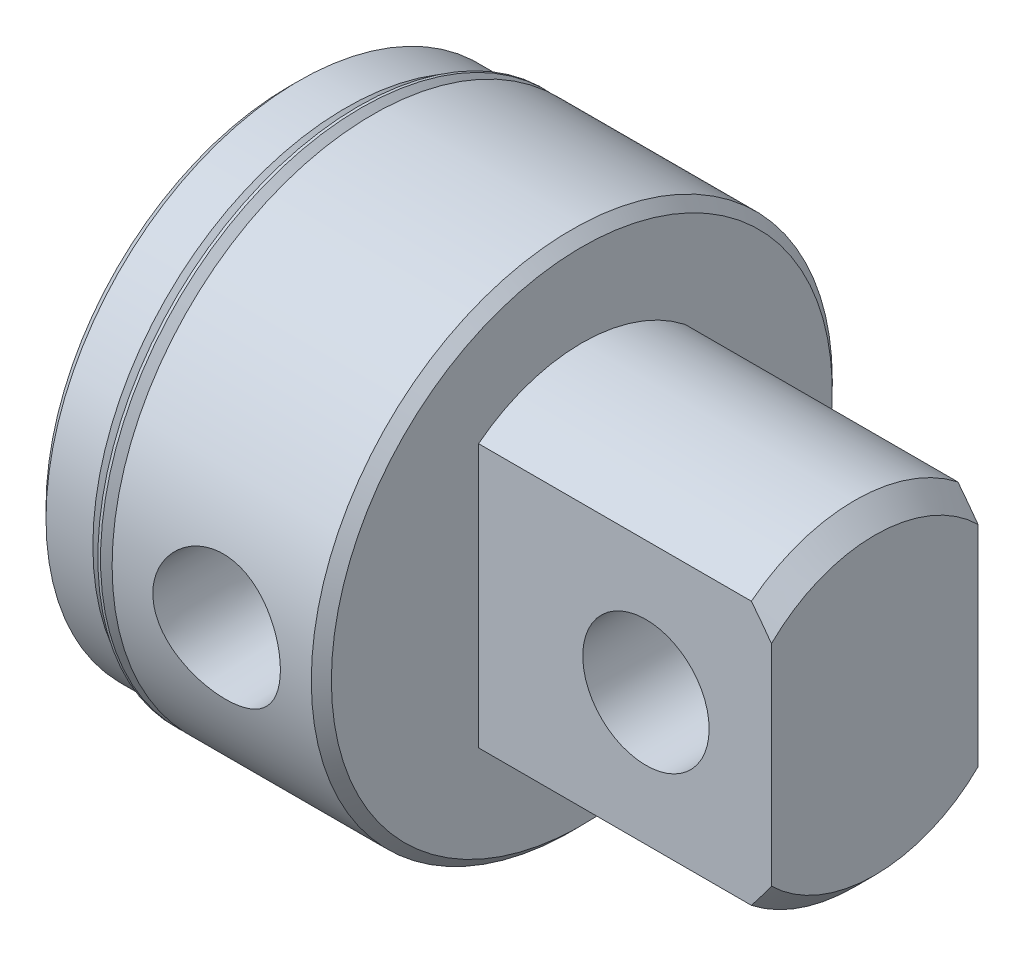
from build123d import *

# Parameters (mm, degrees)
SKETCH3_W               = 79.0702
SKETCH3_H               = 158.1404
SKETCH3_W_2             = 15.6718
SKETCH3_H_2             = 79.0702
CUT_EXTRUDE1_DEPTH      = 22.225
HOLE1_D                 = 13.5128
HOLE1_DEPTH             = 20.45208
HOLE1_TIP               = 3.900809359
SKETCH7_W               = 6.35
SKETCH7_H               = 12.3063
SKETCH9_R               = 4.79425
CUT_EXTRUDE2_DEPTH      = 11.75385
CUT_EXTRUDE2_DEPTH_BACK = 11.75385


with BuildPart() as part:
    # Sketch1 → Revolve1 (revolve)
    with BuildSketch(Plane.XY):
        Polygon((0, 0), (0, 18.43405), (0.762, 19.19605), (4.318, 19.19605), (5.334, 18.18005), (6.35, 18.18005), (6.35, 19.76755), (21.463, 19.76755), (22.225, 19.00555), (22.225, 0), align=None)
    revolve(axis=Axis((22.225, 0, 0), (-1, 0, 0)))

    # Sketch2 → Revolve2 (revolve)
    with BuildSketch(Plane.XY):
        Polygon((22.225, 0), (22.225, 12.7), (42.926, 12.7), (44.45, 11.176), (44.45, 0), align=None)
    revolve(axis=Axis((44.45, 0, 0), (-1, 0, 0)))

    # Sketch3 → Cut-Extrude1 (cut)
    with BuildSketch(Plane(origin=(44.45, 0, 0), x_dir=(0, 0, -1), z_dir=(1, 0, 0))):
        Rectangle(SKETCH3_W, SKETCH3_H)
        Rectangle(SKETCH3_W_2, SKETCH3_H_2, mode=Mode.SUBTRACT)
    extrude(amount=-CUT_EXTRUDE1_DEPTH, mode=Mode.SUBTRACT)

    # Hole1
    with Locations(Plane.ZY):
        with Locations((0, 0)):
            Hole(HOLE1_D / 2, depth=HOLE1_DEPTH)
            with Locations((0, 0, -(HOLE1_DEPTH + HOLE1_TIP / 2))):  # 120° drill point
                Cone(0, HOLE1_D / 2, HOLE1_TIP, mode=Mode.SUBTRACT)

    # Sketch6 → Cut-Revolve1 (revolve, cut)
    with BuildSketch(Plane(origin=(0, 0, 0), x_dir=(-1, 0, 0), z_dir=(0, 0.999847695, 0.017452406))):
        Polygon((-14.2748, 0), (-18.897793378, 0), (-18.897793378, 12.83335), (-19.114275925, 19.76755), (-14.2748, 19.76755), align=None)
    revolve(axis=Axis((14.2748, -0.344991317, 19.764539306), (0, 0.017452406, -0.999847695)), mode=Mode.SUBTRACT)

    # Sketch7 → Cut-Revolve2 (revolve, cut)
    with BuildSketch(Plane.XY):
        with Locations((3.175, 6.15315)):
            Rectangle(SKETCH7_W, SKETCH7_H)
    revolve(axis=Axis((6.35, 0, 0), (-1, 0, 0)), mode=Mode.SUBTRACT)

    # Sketch8 → Revolve3 (revolve)
    with BuildSketch(Plane.XY):
        with BuildLine():
            Line((5.267509175, 19.683381804), (6.216617928, 18.734273051))
            ThreePointArc((6.216617928, 18.734273051), (6.253815367, 18.64447049), (6.216617928, 18.554667928))
            Line((6.216617928, 18.554667928), (5.842, 18.18005))
            Line((5.842, 18.18005), (5.334, 18.18005))
            Line((5.334, 18.18005), (5.334, 17.92605))
            Line((5.334, 17.92605), (6.35, 17.92605))
            Line((6.35, 17.92605), (6.35, 18.888259175))
            Line((6.35, 18.888259175), (5.470709175, 19.76755))
            Line((5.470709175, 19.76755), (5.267509175, 19.76755))
            Line((5.267509175, 19.76755), (5.267509175, 19.683381804))
        make_face()
    revolve(axis=Axis((6.35, 0, 0), (-1, 0, 0)))

    # Sketch9 → Cut-Extrude2 (cut, two sides)
    with BuildSketch(Plane.XY) as cut_extrude2_sk:
        with Locations((34.925, 0)):
            Circle(SKETCH9_R)
    extrude(amount=CUT_EXTRUDE2_DEPTH, mode=Mode.SUBTRACT)
    extrude(cut_extrude2_sk.sketch, amount=-CUT_EXTRUDE2_DEPTH_BACK, mode=Mode.SUBTRACT)


solid = part.part
